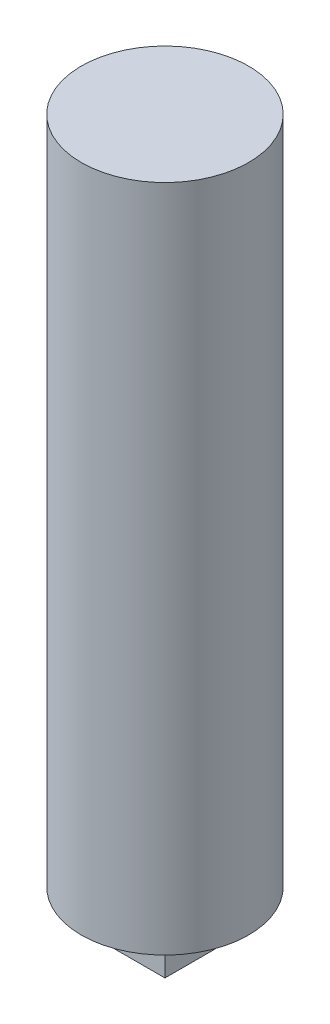
from build123d import *

# Parameters (mm, degrees)
SKETCH1_R           = 6.25
BOSS_EXTRUDE1_DEPTH = 50
SKETCH2_R           = 4.5
CUT_EXTRUDE1_DEPTH  = 1
SKETCH3_W           = 3.8
SKETCH3_H           = 3.8
BOSS_EXTRUDE2_DEPTH = 5


with BuildPart() as part:
    # Sketch1 → Boss-Extrude1 (new body)
    with BuildSketch(Plane(origin=(0, 0, 0), x_dir=(1, 0, 0), z_dir=(0, 1, 0))):
        Circle(SKETCH1_R)
    extrude(amount=BOSS_EXTRUDE1_DEPTH)

    # Sketch2 → Cut-Extrude1 (cut)
    with BuildSketch(Plane.XZ):
        Circle(SKETCH2_R)
    extrude(amount=-CUT_EXTRUDE1_DEPTH, mode=Mode.SUBTRACT)

    # Sketch3 → Boss-Extrude2 (add)
    with BuildSketch(Plane(origin=(0, 1, 0), x_dir=(-1, 0, 0), z_dir=(0, -1, 0))):
        Rectangle(SKETCH3_W, SKETCH3_H)
    extrude(amount=BOSS_EXTRUDE2_DEPTH)


solid = part.part
